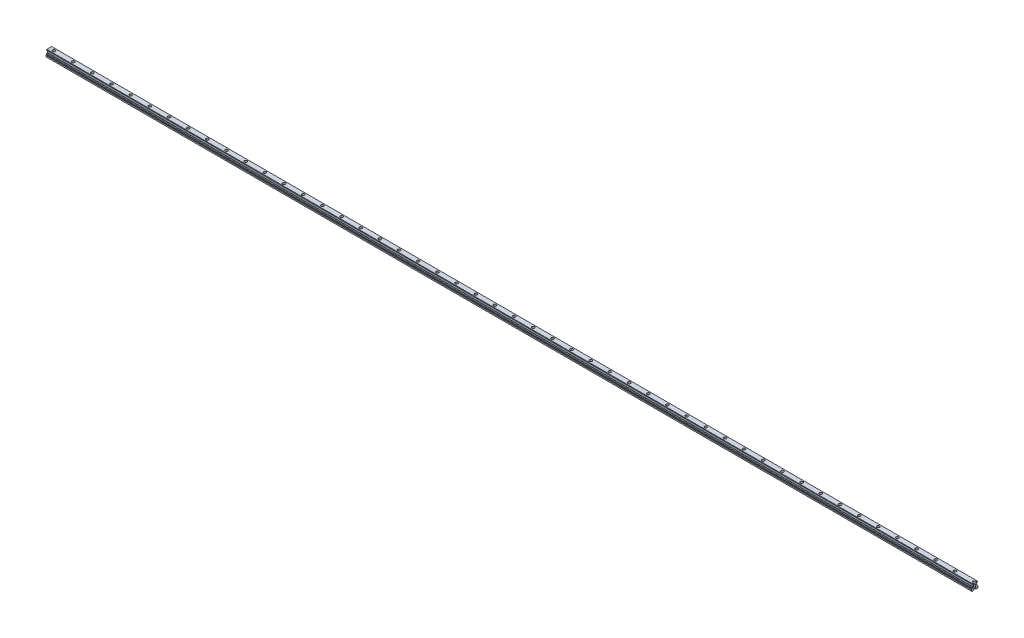
from build123d import *

# Parameters (mm, degrees)
BOSS_EXTRUDE5_DEPTH = 2897
SKETCH8_R           = 4.25
CUT_EXTRUDE1_DEPTH  = 9
SKETCH9_R           = 3
CUT_EXTRUDE2_DEPTH  = 17
LPATTERN1_COUNT     = 50
LPATTERN1_PITCH     = 60


with BuildPart() as part:
    # Sketch7 → Boss-Extrude5 (new body)
    with BuildSketch(Plane(origin=(58.5, 0, 0), x_dir=(0, 0, -1), z_dir=(1, 0, 0))):
        with BuildLine():
            Line((-7.709038211, 8.883084864), (-8.5, 8.601077183))
            Line((-8.5, 8.601077183), (-8.5, 6.104700538))
            ThreePointArc((-8.5, 6.104700538), (-8.566987298, 5.854700538), (-8.75, 5.671687836))
            Line((-8.75, 5.671687836), (-10, 4.95))
            Line((-10, 4.95), (-10, 1))
            Line((-10, 1), (-9, 0))
            Line((-9, 0), (-4, 0))
            Line((-4, 0), (-3.5, 0.5))
            Line((-3.5, 0.5), (3.5, 0.5))
            Line((3.5, 0.5), (4, 0))
            Line((4, 0), (9, 0))
            Line((9, 0), (10, 1))
            Line((10, 1), (10, 4.95))
            Line((10, 4.95), (8.75, 5.671687836))
            ThreePointArc((8.75, 5.671687836), (8.566987298, 5.854700538), (8.5, 6.104700538))
            Line((8.5, 6.104700538), (8.5, 8.46691323))
            Line((8.5, 8.46691323), (8.084678947, 8.882234283))
            ThreePointArc((8.084678947, 8.882234283), (6.941822875, 9.249266637), (6.503340774, 10.366659226))
            Line((6.503340774, 10.366659226), (6, 10.87))
            Line((6, 10.87), (6, 14.93))
            Line((6, 14.93), (6.503340774, 15.433340774))
            ThreePointArc((6.503340774, 15.433340774), (6.813545517, 16.412959034), (7.709038211, 16.916915136))
            Line((7.709038211, 16.916915136), (8.5, 17.198922817))
            Line((8.5, 17.198922817), (8.5, 19.3))
            Line((8.5, 19.3), (7.5, 20.3))
            Line((7.5, 20.3), (-7.5, 20.3))
            Line((-7.5, 20.3), (-8.5, 19.3))
            Line((-8.5, 19.3), (-8.5, 17.33308677))
            Line((-8.5, 17.33308677), (-8.084678947, 16.917765717))
            ThreePointArc((-8.084678947, 16.917765717), (-6.941822875, 16.550733363), (-6.503340774, 15.433340774))
            Line((-6.503340774, 15.433340774), (-6, 14.93))
            Line((-6, 14.93), (-6, 10.87))
            Line((-6, 10.87), (-6.503340774, 10.366659226))
            ThreePointArc((-6.503340774, 10.366659226), (-6.813545517, 9.387040966), (-7.709038211, 8.883084864))
        make_face()
    extrude(amount=BOSS_EXTRUDE5_DEPTH)

    # Sketch8 → Cut-Extrude1 (cut)
    with BuildSketch(Plane(origin=(0, 20.3, 0), x_dir=(1, 0, 0), z_dir=(0, 1, 0))):
        with Locations((73.471629952, 0)):
            Circle(SKETCH8_R)
    cut_extrude1 = extrude(amount=-CUT_EXTRUDE1_DEPTH, mode=Mode.SUBTRACT)

    # Sketch9 → Cut-Extrude2 (cut)
    with BuildSketch(Plane(origin=(0, 11.3, 0), x_dir=(1, 0, 0), z_dir=(0, 1, 0))):
        with Locations((73.471629952, 0)):
            Circle(SKETCH9_R)
    cut_extrude2 = extrude(amount=-CUT_EXTRUDE2_DEPTH, mode=Mode.SUBTRACT)

    # LPattern1: Cut-Extrude1, Cut-Extrude2 ×50
    with Locations(*[(i * LPATTERN1_PITCH, 0, 0) for i in range(1, LPATTERN1_COUNT)]):
        add(cut_extrude1, mode=Mode.SUBTRACT)
        add(cut_extrude2, mode=Mode.SUBTRACT)


solid = part.part
